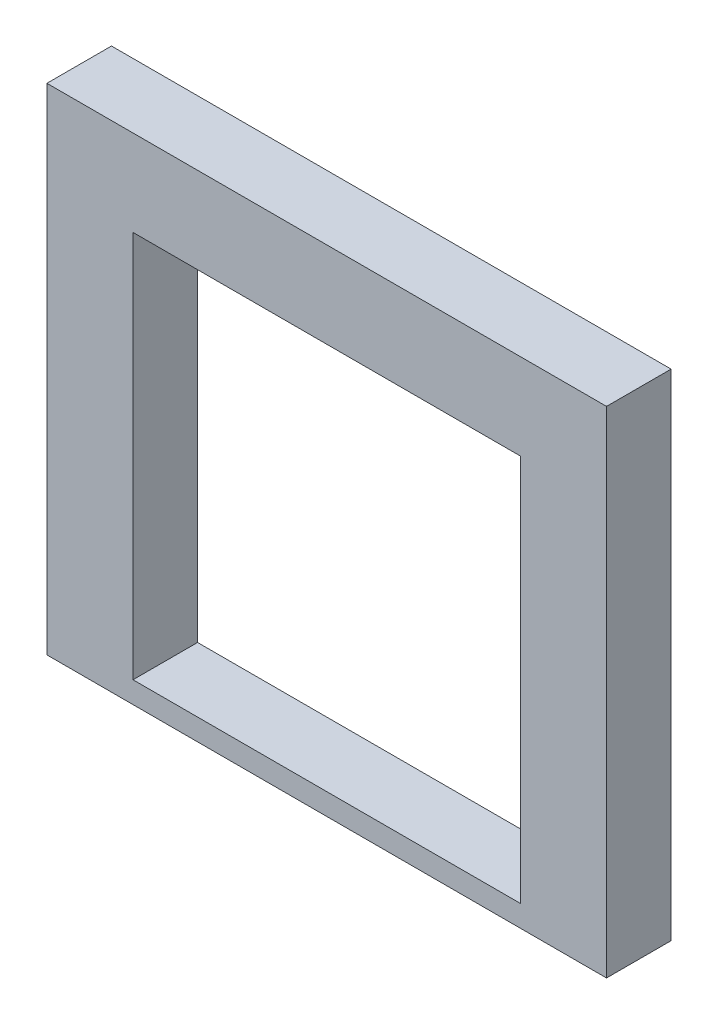
from build123d import *

# Parameters (mm, degrees)
SKETCH1_W           = 13
SKETCH1_H           = 11.5
SKETCH1_W_2         = 9
SKETCH1_H_2         = 9
BOSS_EXTRUDE1_DEPTH = 1.5


with BuildPart() as part:
    # Sketch1 → Boss-Extrude1 (new body)
    with BuildSketch(Plane.XY):
        with Locations((0, 0.75)):
            Rectangle(SKETCH1_W, SKETCH1_H)
        Rectangle(SKETCH1_W_2, SKETCH1_H_2, mode=Mode.SUBTRACT)
    extrude(amount=BOSS_EXTRUDE1_DEPTH)


solid = part.part
